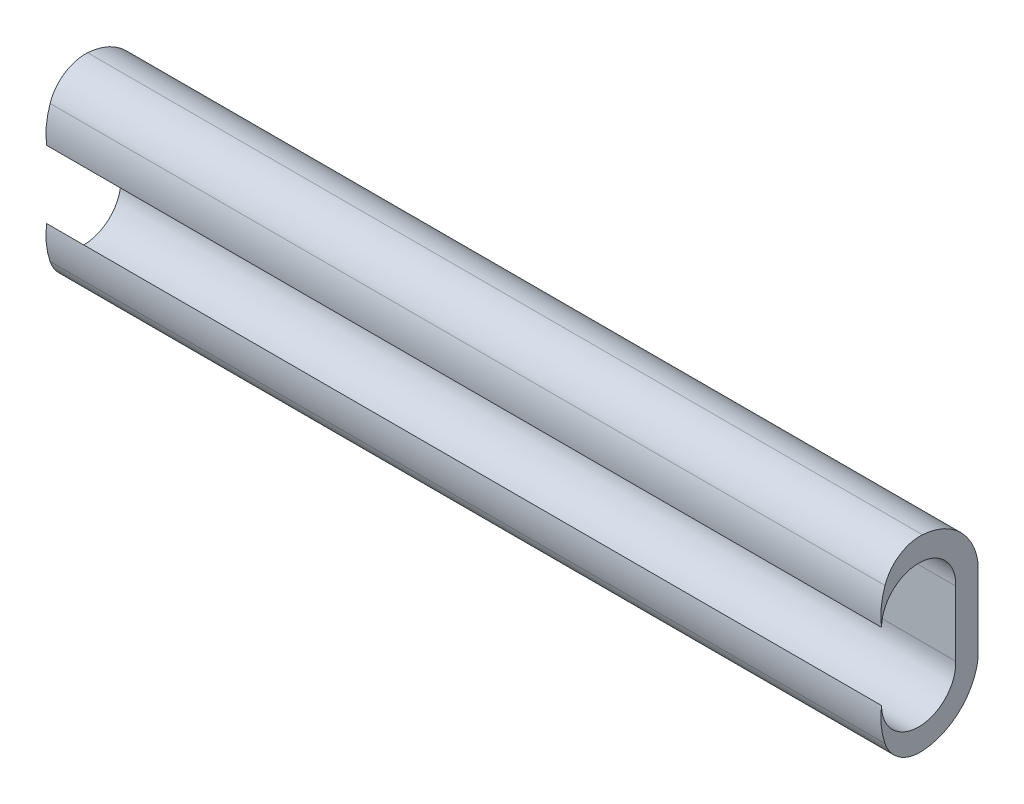
from build123d import *

# Parameters (mm, degrees)
BOSS_EXTRUDE1_DEPTH = 45


with BuildPart() as part:
    # Sketch1 → Boss-Extrude1 (new body)
    with BuildSketch(Plane(origin=(0, 0, 0), x_dir=(0, 0, -1), z_dir=(1, 0, 0))):
        with BuildLine():
            Line((0, 1.752794941), (0, 0))
            Line((0, 0), (1.2, 0))
            Line((1.2, 0), (1.2, 2.25))
            ThreePointArc((1.2, 2.25), (0.204042598, 4.182148799), (-1.79143145, 5.044247083))
            ThreePointArc((-1.79143145, 5.044247083), (-3.03361172, 4.709604832), (-3.814999682, 3.687631197))
            add(Edge.make_bspline(
                [(-3.814999682, 3.687631197), (-4.023588676, 3.069262046), (-4.083460081, 2.438222998), (-3.998734694, 1.823925967)],
                knots=[0.27184632, 0.27184632, 0.27184632, 0.27184632, 0.735422056, 0.735422056, 0.735422056, 0.735422056], degree=3))
            ThreePointArc((-3.998734694, 1.823925967), (-2.034305834, 3.823609616), (0, 1.895056993))
            ThreePointArc((0, 1.895056993), (0.000948954, 1.859497107), (0.001265306, 1.823925967))
            ThreePointArc((0.001265306, 1.823925967), (0.000948954, 1.788354828), (0, 1.752794941))
        make_face()
    extrude(amount=-BOSS_EXTRUDE1_DEPTH)

    # Mirror1: part across plane


with BuildPart() as part_1:
    add(part.part)
    add(part.part.mirror(Plane(origin=(-45, 0, 0), x_dir=(0, 0, 1), z_dir=(0, -1, 0))))


solid = part_1.part
